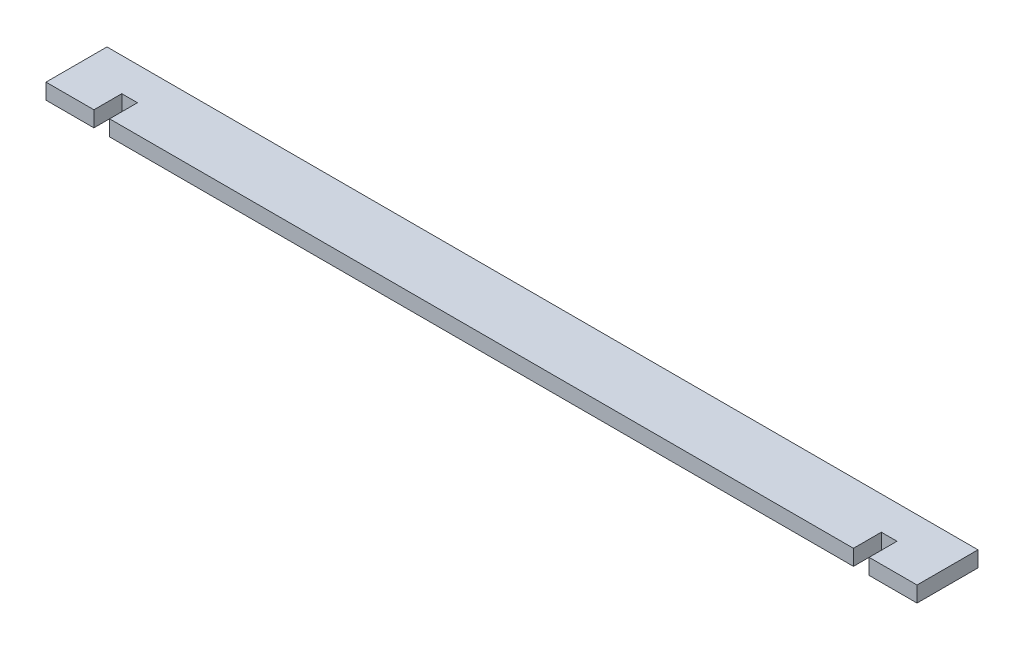
from build123d import *

# Parameters (mm, degrees)
BOSS_EXTRUDE1_DEPTH = 18


with BuildPart() as part:
    # Sketch1 → Boss-Extrude1 (new body)
    with BuildSketch(Plane(origin=(0, 0, 0), x_dir=(1, 0, 0), z_dir=(0, 1, 0))):
        Polygon((0, 0), (-55, 0), (-55, 32), (-73, 32), (-73, 0), (-927, 0), (-927, 32), (-945, 32), (-945, 0), (-1000, 0), (-1000, 70), (0, 70), align=None)
    extrude(amount=BOSS_EXTRUDE1_DEPTH)


solid = part.part
